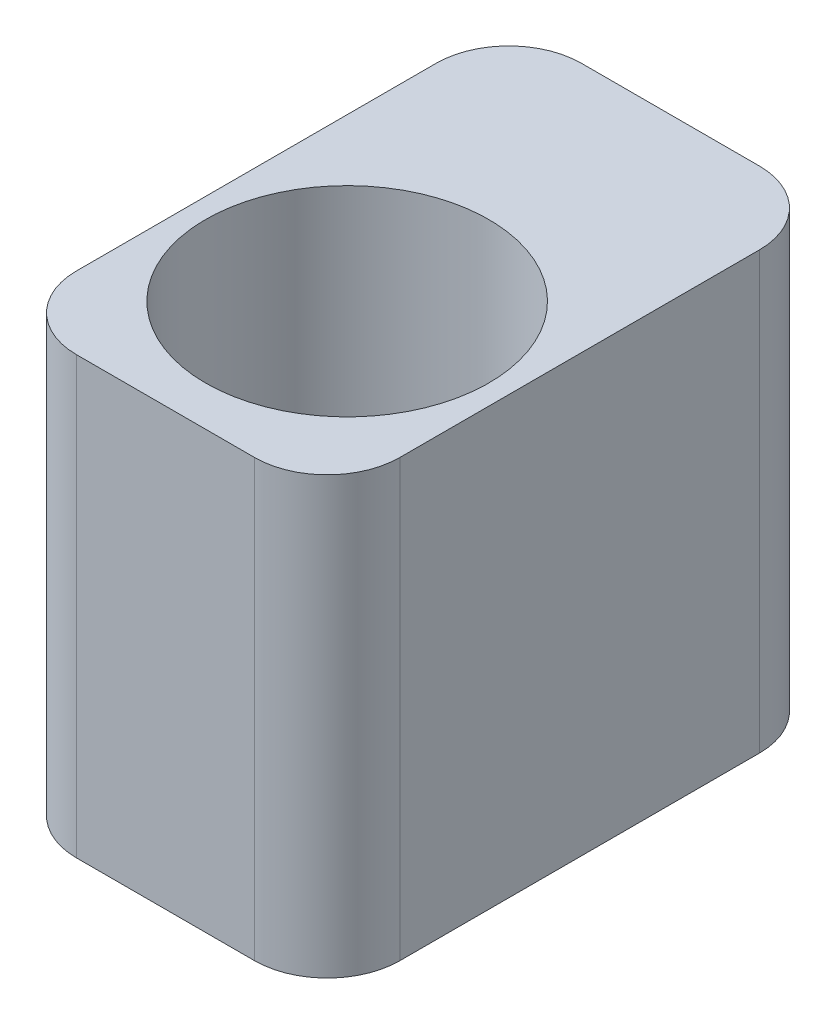
from build123d import *

# Parameters (mm, degrees)
SKETCH_1_R      = 19.5
EXTRUDE_1_DEPTH = 60
FILLET_1_R      = 10


with BuildPart() as part:
    # 草图1 → 凸台-拉伸1 (new body)
    with BuildSketch(Plane(origin=(0, 0, 0), x_dir=(1, 0, 0), z_dir=(0, 1, 0))):
        Polygon((-22.25, 22.25), (22.25, 22.25), (22.25, -22.25), (22.25, -47.25), (-22.25, -47.25), (-22.25, -22.25), align=None)
        with Locations((0, -22.25)):
            Circle(SKETCH_1_R, mode=Mode.SUBTRACT)
    extrude(amount=EXTRUDE_1_DEPTH)

    # 圆角1
    fillet_1_edges = [part.edges().sort_by_distance(p)[0] for p in [
        (22.25, 30, 47.25),
        (-22.25, 30, 47.25),
        (-22.25, 30, -22.25),
        (22.25, 30, -22.25),
    ]]
    fillet(fillet_1_edges, radius=FILLET_1_R)


solid = part.part
